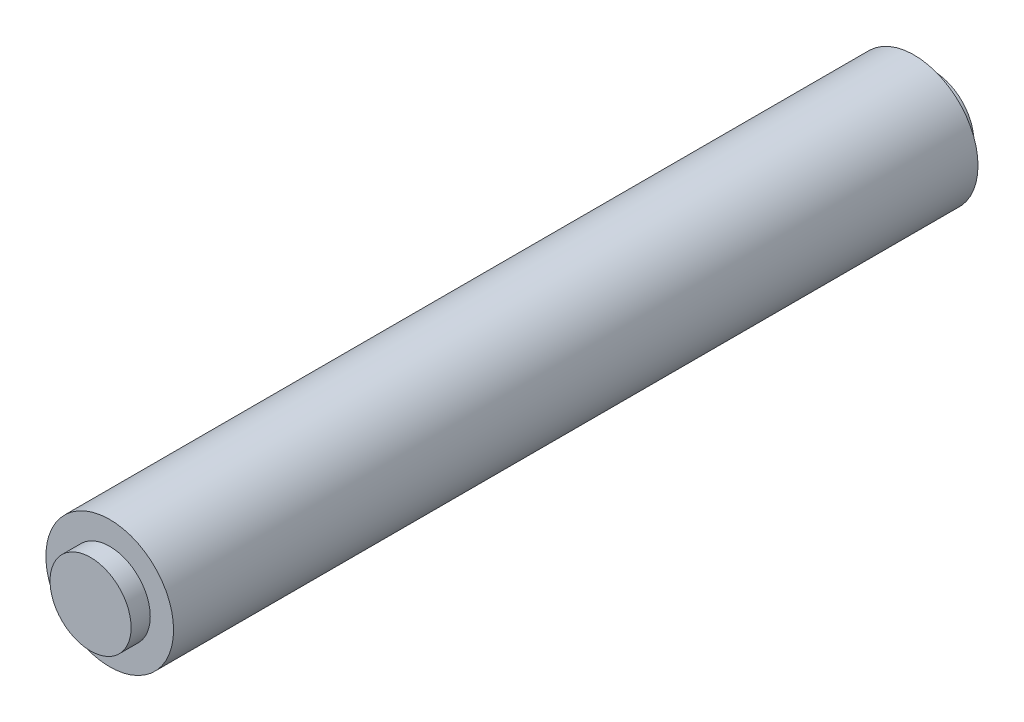
from build123d import *

# Parameters (mm, degrees)
SKETCH1_R           = 3.175
BOSS_EXTRUDE1_DEPTH = 33
SKETCH2_R           = 5
BOSS_EXTRUDE2_DEPTH = 31.5


with BuildPart() as part:
    # Sketch1 → Boss-Extrude1 (new body, symmetric)
    with BuildSketch(Plane.XY):
        Circle(SKETCH1_R)
    extrude(amount=BOSS_EXTRUDE1_DEPTH, both=True)


with BuildPart() as body_2:
    # Sketch2 → Boss-Extrude2 (new body, symmetric)
    with BuildSketch(Plane.XY):
        Circle(SKETCH2_R)
    extrude(amount=BOSS_EXTRUDE2_DEPTH, both=True)


solid = Compound([part.part, body_2.part])
